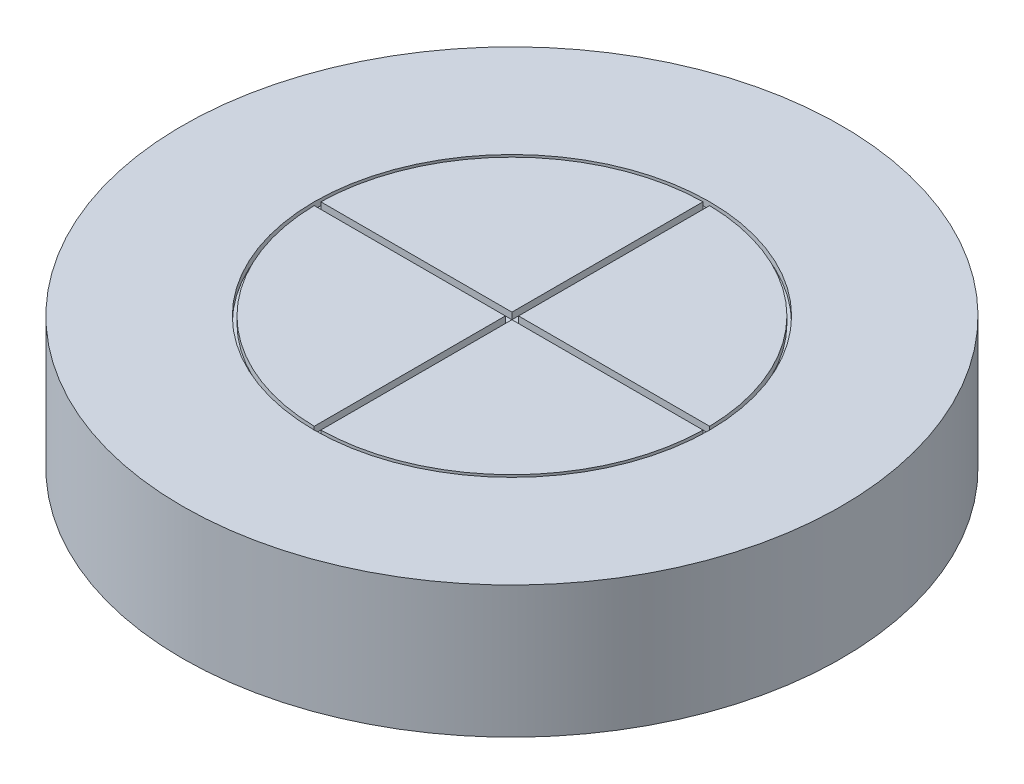
from build123d import *

# Parameters (mm, degrees)
SKETCH2_R                                = 50
BOSS_EXTRUDE2_DEPTH                      = 20
SKETCH1_R                                = 30
CUT_EXTRUDE1_DEPTH                       = 1
F_60_0_04_DIAMETER_HOLE1_D               = 1.016
F_60_0_04_DIAMETER_HOLE1_DEPTH           = 10
F_60_0_04_DIAMETER_HOLE1_TIP             = 0.305237194
F_60_0_04_DIAMETER_HOLE1_ON_FACE_2_D     = 1.016
F_60_0_04_DIAMETER_HOLE1_ON_FACE_2_DEPTH = 10
F_60_0_04_DIAMETER_HOLE1_ON_FACE_2_TIP   = 0.305237194
F_2_0_221_DIAMETER_HOLE1_D               = 5.6134
F_2_0_221_DIAMETER_HOLE1_DEPTH           = 55
F_2_0_221_DIAMETER_HOLE1_TIP             = 1.686435499


with BuildPart() as part:
    # Sketch2 → Boss-Extrude2 (new body)
    with BuildSketch(Plane(origin=(0, 0, 0), x_dir=(1, 0, 0), z_dir=(0, 1, 0))):
        Circle(SKETCH2_R)
    extrude(amount=-BOSS_EXTRUDE2_DEPTH)

    # Sketch1 → Cut-Extrude1 (cut)
    with BuildSketch(Plane(origin=(0, 0, 0), x_dir=(1, 0, 0), z_dir=(0, 1, 0))):
        Circle(SKETCH1_R)
        with BuildLine():
            Line((-0.5, -0.5), (-0.5, -29.495762408))
            ThreePointArc((-0.5, -29.495762408), (-20.859650045, -20.859650045), (-29.495762408, -0.5))
            Line((-29.495762408, -0.5), (-0.5, -0.5))
        make_face(mode=Mode.SUBTRACT)
        with BuildLine():
            ThreePointArc((29.495762408, -0.5), (20.859650045, -20.859650045), (0.5, -29.495762408))
            Line((0.5, -29.495762408), (0.5, -0.5))
            Line((0.5, -0.5), (29.495762408, -0.5))
        make_face(mode=Mode.SUBTRACT)
        with BuildLine():
            Line((-0.5, 29.495762408), (-0.5, 0.5))
            Line((-0.5, 0.5), (-29.495762408, 0.5))
            ThreePointArc((-29.495762408, 0.5), (-20.859650045, 20.859650045), (-0.5, 29.495762408))
        make_face(mode=Mode.SUBTRACT)
        with BuildLine():
            Line((29.495762408, 0.5), (0.5, 0.5))
            Line((0.5, 0.5), (0.5, 29.495762408))
            ThreePointArc((0.5, 29.495762408), (20.859650045, 20.859650045), (29.495762408, 0.5))
        make_face(mode=Mode.SUBTRACT)
    extrude(amount=-CUT_EXTRUDE1_DEPTH, mode=Mode.SUBTRACT)

    # #60 (0.04) Diameter Hole1
    with Locations(Plane(origin=(9.64e-06, -1, -4.709e-06), x_dir=(0, 0, 1), z_dir=(0, 1, 0))):
        with Locations((0, 0)):
            Hole(F_60_0_04_DIAMETER_HOLE1_D / 2, depth=F_60_0_04_DIAMETER_HOLE1_DEPTH)
            with Locations((0, 0, -(F_60_0_04_DIAMETER_HOLE1_DEPTH + F_60_0_04_DIAMETER_HOLE1_TIP / 2))):  # 118° drill point
                Cone(0, F_60_0_04_DIAMETER_HOLE1_D / 2, F_60_0_04_DIAMETER_HOLE1_TIP, mode=Mode.SUBTRACT)

    # #60 (0.04) Diameter Hole1 on face 2
    with Locations(Plane.ZX):
        with Locations((0, 0)):
            Hole(F_60_0_04_DIAMETER_HOLE1_ON_FACE_2_D / 2, depth=F_60_0_04_DIAMETER_HOLE1_ON_FACE_2_DEPTH)
            with Locations((0, 0, -(F_60_0_04_DIAMETER_HOLE1_ON_FACE_2_DEPTH + F_60_0_04_DIAMETER_HOLE1_ON_FACE_2_TIP / 2))):  # 118° drill point
                Cone(0, F_60_0_04_DIAMETER_HOLE1_ON_FACE_2_D / 2, F_60_0_04_DIAMETER_HOLE1_ON_FACE_2_TIP, mode=Mode.SUBTRACT)

    # #2 (0.221) Diameter Hole1
    with Locations(Plane(origin=(-50, -9.832744337, 1.0253e-05), x_dir=(-2.05e-07, 0, -1), z_dir=(-1, 0, 2.05e-07))):
        with Locations((0, 0), (1.0253e-05, -1.9e-08)):
            Hole(F_2_0_221_DIAMETER_HOLE1_D / 2, depth=F_2_0_221_DIAMETER_HOLE1_DEPTH)
            with Locations((0, 0, -(F_2_0_221_DIAMETER_HOLE1_DEPTH + F_2_0_221_DIAMETER_HOLE1_TIP / 2))):  # 118° drill point
                Cone(0, F_2_0_221_DIAMETER_HOLE1_D / 2, F_2_0_221_DIAMETER_HOLE1_TIP, mode=Mode.SUBTRACT)

    # Sketch9 → Cut-Revolve1 (revolve, cut)
    with BuildSketch(Plane(origin=(0, -20, 0), x_dir=(-1, 0, 0), z_dir=(0, -1, 0))):
        with BuildLine():
            Line((-5, 0), (5, 0))
            ThreePointArc((5, 0), (0, 5), (-5, 0))
        make_face()
    revolve(axis=Axis((5, -20, 0), (-1, 0, 0)), mode=Mode.SUBTRACT)


solid = part.part
